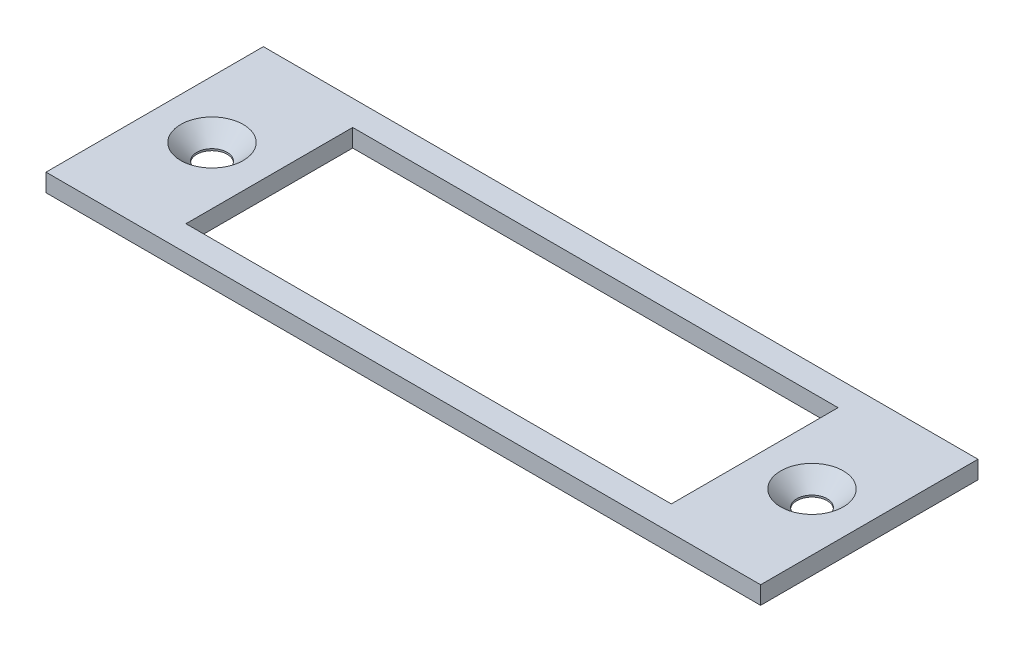
from build123d import *

# Parameters (mm, degrees)
SKETCH1_W                                     = 120
SKETCH1_H                                     = 36.5
BOSS_EXTRUDE1_DEPTH                           = 3
CUT_EXTRUDE1_DEPTH                            = 4
CSK_FOR_5_OVAL_HEAD_MACHINE_SCREW1_AT_2_COUNT = 2
CSK_FOR_5_OVAL_HEAD_MACHINE_SCREW1_AT_2_PITCH = 100.75


with BuildPart() as part:
    # Sketch1 → Boss-Extrude1 (new body)
    with BuildSketch(Plane(origin=(0, 0, 0), x_dir=(1, 0, 0), z_dir=(0, 1, 0))):
        with Locations((60, -18.25)):
            Rectangle(SKETCH1_W, SKETCH1_H)
    extrude(amount=BOSS_EXTRUDE1_DEPTH)

    # Sketch2 → Cut-Extrude1 (cut, through all)
    with BuildSketch(Plane(origin=(0, 3, 0), x_dir=(1, 0, 0), z_dir=(0, 1, 0))):
        Polygon((19.25, -32.25), (100.75, -32.25), (100.75, -4.25), (60, -4.25), (19.25, -4.25), align=None)
    extrude(amount=-CUT_EXTRUDE1_DEPTH, mode=Mode.SUBTRACT)

    # Sketch6 → CSK for #5 Oval Head Machine Screw1 (revolve, cut)
    with BuildSketch(Plane(origin=(9.625, 3, 18.25), x_dir=(0, 0, 1), z_dir=(1, 0, 0))):
        Polygon((0, 0), (0, 3), (2.5499949, 3), (2.5499949, 2.7000073), (5.2500022, 0), align=None)
    csk_for_5_oval_head_machine_screw1 = revolve(axis=Axis((9.625, 9.35, 18.25), (0, -1, 0)), mode=Mode.SUBTRACT)

    # CSK for #5 Oval Head Machine Screw1 at 2: CSK for #5 Oval Head Machine Screw1 ×2
    with Locations(*[(i * CSK_FOR_5_OVAL_HEAD_MACHINE_SCREW1_AT_2_PITCH, 0, 0) for i in range(1, CSK_FOR_5_OVAL_HEAD_MACHINE_SCREW1_AT_2_COUNT)]):
        add(csk_for_5_oval_head_machine_screw1, mode=Mode.SUBTRACT)


solid = part.part
